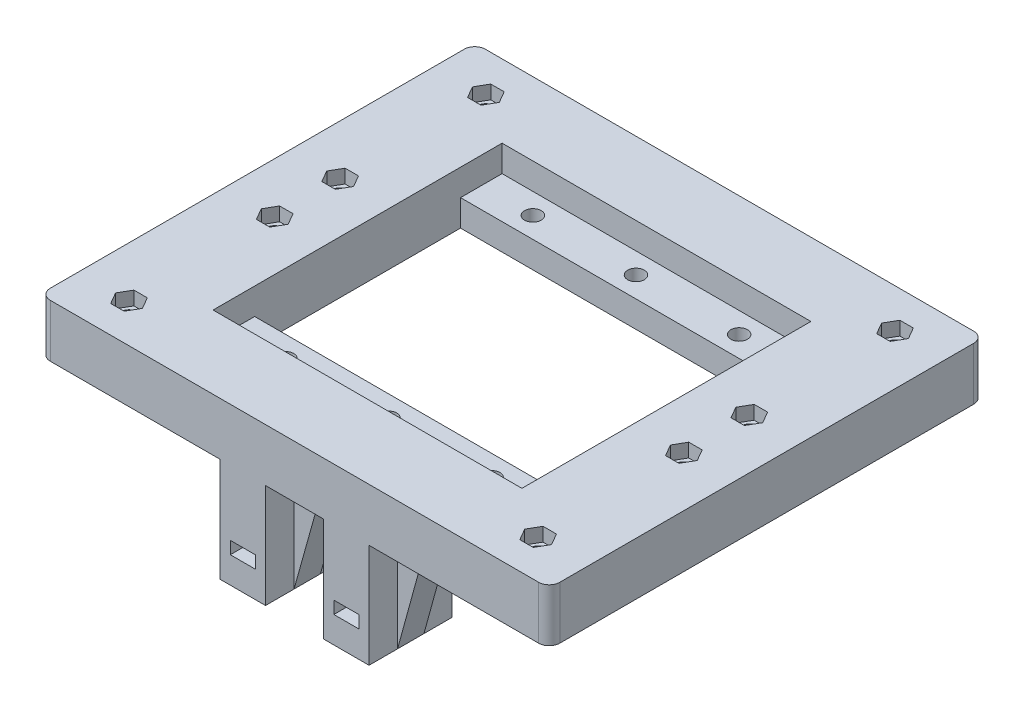
from build123d import *

# Parameters (mm, degrees)
SKETCH2_W            = 122.555
SKETCH2_H            = 104.648
SKETCH2_R            = 2
SKETCH2_W_2          = 74.295
SKETCH2_H_2          = 69.53
BOSS_EXTRUDE5_DEPTH  = 12.7
SKETCH2_4_W          = 74.295
SKETCH2_4_H          = 10
SKETCH2_4_R          = 2
BOSS_EXTRUDE7_DEPTH  = 6.35
CUT_EXTRUDE1_START   = -12.7
SKETCH3_R            = 2
CUT_EXTRUDE1_DEPTH   = 3.302
FILLET1_R            = 2.54
CUT_EXTRUDE2_START   = -6.35
SKETCH4_R            = 2
CUT_EXTRUDE2_DEPTH   = 3.302
SKETCH5_R            = 2
CUT_EXTRUDE3_DEPTH   = 3.302
SKETCH6_R            = 2
CUT_EXTRUDE4_DEPTH   = 3.302
SKETCH7_W            = 10.936
SKETCH7_H            = 20
BOSS_EXTRUDE8_DEPTH  = 25
SKETCH8_R            = 2
CUT_EXTRUDE6_DEPTH   = 19.05
BOSS_EXTRUDE9_START  = -10.033
BOSS_EXTRUDE9_DEPTH  = 3.175
SKETCH10_W           = 6
SKETCH10_H           = 3
CUT_EXTRUDE7_DEPTH   = 8.382
CUT_EXTRUDE15_START  = -20
SKETCH10_3_W         = 6
SKETCH10_3_H         = 3
CUT_EXTRUDE15_DEPTH  = 8.382
SKETCH5_2_R          = 2
BOSS_EXTRUDE10_DEPTH = 6.35
SKETCH6_2_R          = 2
BOSS_EXTRUDE11_DEPTH = 12.7


with BuildPart() as part:
    # Sketch2 → Boss-Extrude5 (new body)
    with BuildSketch(Plane(origin=(0, 0, 0), x_dir=(1, 0, 0), z_dir=(0, 1, 0))):
        with Locations((61.2775, 52.324)):
            Rectangle(SKETCH2_W, SKETCH2_H)
        with Locations(Location((12.065, 95.25, 0), (0, 0, 270))):
            Circle(SKETCH2_R, mode=Mode.SUBTRACT)
        with Locations(Location((12.065, 60.198, 0), (0, 0, 270))):
            Circle(SKETCH2_R, mode=Mode.SUBTRACT)
        with Locations(Location((12.065, 44.45, 0), (0, 0, 270))):
            Circle(SKETCH2_R, mode=Mode.SUBTRACT)
        with Locations(Location((12.065, 9.398, 0), (0, 0, 270))):
            Circle(SKETCH2_R, mode=Mode.SUBTRACT)
        with Locations(Location((110.49, 9.398, 0), (0, 0, 270))):
            Circle(SKETCH2_R, mode=Mode.SUBTRACT)
        with Locations(Location((110.49, 44.45, 0), (0, 0, 270))):
            Circle(SKETCH2_R, mode=Mode.SUBTRACT)
        with Locations(Location((110.49, 60.198, 0), (0, 0, 270))):
            Circle(SKETCH2_R, mode=Mode.SUBTRACT)
        with Locations(Location((110.49, 95.25, 0), (0, 0, 270))):
            Circle(SKETCH2_R, mode=Mode.SUBTRACT)
        with Locations(Location((73.744666667, 5.08, 0), (0, 0, 270))):
            Circle(SKETCH2_R, mode=Mode.SUBTRACT)
        with Locations(Location((48.839129454, 5.150105129, 0), (0, 0, 270))):
            Circle(SKETCH2_R, mode=Mode.SUBTRACT)
        with Locations((61.2775, 52.324)):
            Rectangle(SKETCH2_W_2, SKETCH2_H_2, mode=Mode.SUBTRACT)
    extrude(amount=BOSS_EXTRUDE5_DEPTH)

    # Sketch2_4 → Boss-Extrude7 (add)
    with BuildSketch(Plane(origin=(0, 0, 0), x_dir=(1, 0, 0), z_dir=(0, 1, 0))):
        with Locations((61.2775, 22.559)):
            Rectangle(SKETCH2_4_W, SKETCH2_4_H)
        with Locations(Location((36.533666667, 22.559, 0), (0, 0, 270))):
            Circle(SKETCH2_4_R, mode=Mode.SUBTRACT)
        with Locations(Location((48.939224409, 22.929823378, 0), (0, 0, 270))):
            Circle(SKETCH2_4_R, mode=Mode.SUBTRACT)
        with Locations(Location((61.341, 22.559, 0), (0, 0, 270))):
            Circle(SKETCH2_4_R, mode=Mode.SUBTRACT)
        with Locations(Location((73.744666667, 22.86, 0), (0, 0, 270))):
            Circle(SKETCH2_4_R, mode=Mode.SUBTRACT)
        with Locations(Location((86.148333333, 22.559, 0), (0, 0, 270))):
            Circle(SKETCH2_4_R, mode=Mode.SUBTRACT)
        with Locations((61.2775, 82.089)):
            Rectangle(SKETCH2_4_W, SKETCH2_4_H)
        with Locations(Location((36.533666667, 82.089, 0), (0, 0, 270))):
            Circle(SKETCH2_4_R, mode=Mode.SUBTRACT)
        with Locations(Location((61.341, 82.089, 0), (0, 0, 270))):
            Circle(SKETCH2_4_R, mode=Mode.SUBTRACT)
        with Locations(Location((86.148333333, 82.089, 0), (0, 0, 270))):
            Circle(SKETCH2_4_R, mode=Mode.SUBTRACT)
    extrude(amount=BOSS_EXTRUDE7_DEPTH)

    # Sketch3 → Cut-Extrude1 (cut)
    with BuildSketch(Plane.XZ.offset(CUT_EXTRUDE1_START)):
        Polygon((13.678116652, -6.604), (10.451883348, -6.604), (8.838766696, -9.398), (10.451883348, -12.192), (13.678116652, -12.192), (15.291233304, -9.398), align=None)
        with Locations(Location((12.065, -9.398, 0), (0, 0, 90))):
            Circle(SKETCH3_R, mode=Mode.SUBTRACT)
        Polygon((13.678116652, -92.456), (10.451883348, -92.456), (8.838766696, -95.25), (10.451883348, -98.044), (13.678116652, -98.044), (15.291233304, -95.25), align=None)
        with Locations(Location((12.065, -95.25, 0), (0, 0, 90))):
            Circle(SKETCH3_R, mode=Mode.SUBTRACT)
        Polygon((112.103116652, -92.456), (108.876883348, -92.456), (107.263766696, -95.25), (108.876883348, -98.044), (112.103116652, -98.044), (113.716233304, -95.25), align=None)
        with Locations(Location((110.49, -95.25, 0), (0, 0, 90))):
            Circle(SKETCH3_R, mode=Mode.SUBTRACT)
        Polygon((108.876883348, -12.192), (112.103116652, -12.192), (113.716233304, -9.398), (112.103116652, -6.604), (108.876883348, -6.604), (107.263766696, -9.398), align=None)
        with Locations(Location((110.49, -9.398, 0), (0, 0, 90))):
            Circle(SKETCH3_R, mode=Mode.SUBTRACT)
        Polygon((13.678116652, -62.992), (15.291233304, -60.198), (13.678116652, -57.404), (10.451883348, -57.404), (8.838766696, -60.198), (10.451883348, -62.992), align=None)
        with Locations(Location((12.065, -60.198, 0), (0, 0, 90))):
            Circle(SKETCH3_R, mode=Mode.SUBTRACT)
        Polygon((8.838766696, -44.45), (10.451883348, -47.244), (13.678116652, -47.244), (15.291233304, -44.45), (13.678116652, -41.656), (10.451883348, -41.656), align=None)
        with Locations(Location((12.065, -44.45, 0), (0, 0, 90))):
            Circle(SKETCH3_R, mode=Mode.SUBTRACT)
        Polygon((107.263766696, -44.45), (108.876883348, -47.244), (112.103116652, -47.244), (113.716233304, -44.45), (112.103116652, -41.656), (108.876883348, -41.656), align=None)
        with Locations(Location((110.49, -44.45, 0), (0, 0, 90))):
            Circle(SKETCH3_R, mode=Mode.SUBTRACT)
        Polygon((108.876883348, -57.404), (107.263766696, -60.198), (108.876883348, -62.992), (112.103116652, -62.992), (113.716233304, -60.198), (112.103116652, -57.404), align=None)
        with Locations(Location((110.49, -60.198, 0), (0, 0, 90))):
            Circle(SKETCH3_R, mode=Mode.SUBTRACT)
    extrude(amount=CUT_EXTRUDE1_DEPTH, mode=Mode.SUBTRACT)

    # Fillet1
    fillet1_edges = [part.edges().sort_by_distance(p)[0] for p in [
        (0, 6.35, 0),
        (0, 6.35, -104.648),
        (122.555, 6.35, -104.648),
        (122.555, 6.35, 0),
    ]]
    fillet(fillet1_edges, radius=FILLET1_R)

    # Sketch4 → Cut-Extrude2 (cut)
    with BuildSketch(Plane(origin=(0, 6.35, 0), x_dir=(1, 0, 0), z_dir=(0, 1, 0)).offset(CUT_EXTRUDE2_START)):
        Polygon((39.759899971, 22.559), (38.146783319, 25.353), (34.920550015, 25.353), (33.307433362, 22.559), (34.920550015, 19.765), (38.146783319, 19.765), align=None)
        with Locations(Location((36.533666667, 22.559, 0), (0, 0, 270))):
            Circle(SKETCH4_R, mode=Mode.SUBTRACT)
        Polygon((58.114766696, 22.559), (59.727883348, 19.765), (62.954116652, 19.765), (64.567233304, 22.559), (62.954116652, 25.353), (59.727883348, 25.353), align=None)
        with Locations(Location((61.341, 22.559, 0), (0, 0, 270))):
            Circle(SKETCH4_R, mode=Mode.SUBTRACT)
        Polygon((82.922100029, 22.559), (84.535216681, 19.765), (87.761449985, 19.765), (89.374566638, 22.559), (87.761449985, 25.353), (84.535216681, 25.353), align=None)
        with Locations(Location((86.148333333, 22.559, 0), (0, 0, 270))):
            Circle(SKETCH4_R, mode=Mode.SUBTRACT)
        Polygon((82.922100029, 82.089), (84.535216681, 79.295), (87.761449985, 79.295), (89.374566638, 82.089), (87.761449985, 84.883), (84.535216681, 84.883), align=None)
        with Locations(Location((86.148333333, 82.089, 0), (0, 0, 270))):
            Circle(SKETCH4_R, mode=Mode.SUBTRACT)
        Polygon((64.567233304, 82.089), (62.954116652, 84.883), (59.727883348, 84.883), (58.114766696, 82.089), (59.727883348, 79.295), (62.954116652, 79.295), align=None)
        with Locations(Location((61.341, 82.089, 0), (0, 0, 270))):
            Circle(SKETCH4_R, mode=Mode.SUBTRACT)
        Polygon((39.759899971, 82.089), (38.146783319, 84.883), (34.920550015, 84.883), (33.307433362, 82.089), (34.920550015, 79.295), (38.146783319, 79.295), align=None)
        with Locations(Location((36.533666667, 82.089, 0), (0, 0, 270))):
            Circle(SKETCH4_R, mode=Mode.SUBTRACT)
    extrude(amount=CUT_EXTRUDE2_DEPTH, mode=Mode.SUBTRACT)

    # Sketch5 → Cut-Extrude3 (cut)
    with BuildSketch(Plane(origin=(0, 6.35, 0), x_dir=(1, 0, 0), z_dir=(0, 1, 0))):
        with Locations(Location((48.839129454, 5.150105129, 0), (0, 0, 270))):
            Circle(SKETCH5_R)
        with Locations(Location((73.744666667, 5.08, 0), (0, 0, 270))):
            Circle(SKETCH5_R)
        Polygon((76.970899971, 22.86), (75.357783319, 25.654), (72.131550015, 25.654), (70.518433362, 22.86), (72.131550015, 20.066), (75.357783319, 20.066), align=None)
        with Locations(Location((73.744666667, 22.86, 0), (0, 0, 270))):
            Circle(SKETCH5_R, mode=Mode.SUBTRACT)
        Polygon((52.165457714, 22.929823378), (50.552341061, 25.723823378), (47.326107757, 25.723823378), (45.712991105, 22.929823378), (47.326107757, 20.135823378), (50.552341061, 20.135823378), align=None)
        with Locations(Location((48.939224409, 22.929823378, 0), (0, 0, 270))):
            Circle(SKETCH5_R, mode=Mode.SUBTRACT)
    extrude(amount=-CUT_EXTRUDE3_DEPTH, mode=Mode.SUBTRACT)

    # Sketch6 → Cut-Extrude4 (cut)
    with BuildSketch(Plane(origin=(0, 12.7, 0), x_dir=(1, 0, 0), z_dir=(0, 1, 0))):
        Polygon((70.518433362, 5.08), (72.131550015, 2.286), (75.357783319, 2.286), (76.970899971, 5.08), (75.357783319, 7.874), (72.131550015, 7.874), align=None)
        with Locations(Location((73.744666667, 5.08, 0), (0, 0, 270))):
            Circle(SKETCH6_R, mode=Mode.SUBTRACT)
        Polygon((45.612896149, 5.150105129), (47.226012801, 2.356105129), (50.452246106, 2.356105129), (52.065362758, 5.150105129), (50.452246106, 7.944105129), (47.226012801, 7.944105129), align=None)
        with Locations(Location((48.839129454, 5.150105129, 0), (0, 0, 270))):
            Circle(SKETCH6_R, mode=Mode.SUBTRACT)
    extrude(amount=-CUT_EXTRUDE4_DEPTH, mode=Mode.SUBTRACT)

    # Sketch7 → Boss-Extrude8 (add)
    with BuildSketch(Plane.XZ):
        with Locations((48.839129454, -10)):
            Rectangle(SKETCH7_W, SKETCH7_H)
        with Locations((73.744666667, -10)):
            Rectangle(SKETCH7_W, SKETCH7_H)
    extrude(amount=BOSS_EXTRUDE8_DEPTH)

    # Sketch8 → Cut-Extrude6 (cut)
    with BuildSketch(Plane.XZ.offset(25)):
        with Locations(Location((48.839129454, -15.310105129, 0), (0, 0, 270))):
            Circle(SKETCH8_R)
        with Locations(Location((48.839129454, -5.150105129, 0), (0, 0, 270))):
            Circle(SKETCH8_R)
        with Locations(Location((73.744666667, -5.08, 0), (0, 0, 90))):
            Circle(SKETCH8_R)
        with Locations(Location((73.744666667, -15.310105129, 0), (0, 0, 270))):
            Circle(SKETCH8_R)
    extrude(amount=-CUT_EXTRUDE6_DEPTH, mode=Mode.SUBTRACT)

    # Sketch9 → Boss-Extrude9 (add, symmetric)
    with BuildSketch(Plane.XY.offset(BOSS_EXTRUDE9_START)):
        Polygon((68.276666667, 0), (61.29189806, 0), (68.276666667, -25), align=None)
        Polygon((79.212666667, 0), (79.212666667, -25), (86.070666667, 0), align=None)
        Polygon((54.307129454, 0), (54.307129454, -25), (61.29189806, 0), align=None)
        Polygon((43.371129454, 0), (36.513129454, 0), (43.371129454, -25), align=None)
    extrude(amount=BOSS_EXTRUDE9_DEPTH, both=True)

    # Sketch10 → Cut-Extrude7 (cut)
    with BuildSketch(Plane.XY):
        with Locations((48.839129454, -17.15)):
            Rectangle(SKETCH10_W, SKETCH10_H)
        with Locations((73.744666667, -17.15)):
            Rectangle(SKETCH10_W, SKETCH10_H)
    extrude(amount=-CUT_EXTRUDE7_DEPTH, mode=Mode.SUBTRACT)

    # Sketch10_3 → Cut-Extrude15 (cut)
    with BuildSketch(Plane.XY.offset(CUT_EXTRUDE15_START)):
        with Locations((48.839129454, -17.15)):
            Rectangle(SKETCH10_3_W, SKETCH10_3_H)
        with Locations((73.744666667, -17.15)):
            Rectangle(SKETCH10_3_W, SKETCH10_3_H)
    extrude(amount=CUT_EXTRUDE15_DEPTH, mode=Mode.SUBTRACT)

    # Sketch5_2 → Boss-Extrude10 (add)
    with BuildSketch(Plane(origin=(0, 6.35, 0), x_dir=(1, 0, 0), z_dir=(0, 1, 0))):
        Polygon((47.326107757, 20.135823378), (50.552341061, 20.135823378), (52.165457714, 22.929823378), (50.552341061, 25.723823378), (47.326107757, 25.723823378), (45.712991105, 22.929823378), align=None)
        with Locations((48.939224409, 22.929823378)):
            Circle(SKETCH5_2_R, mode=Mode.SUBTRACT)
        with Locations((48.939224409, 22.929823378)):
            Circle(SKETCH5_2_R)
        Polygon((72.131550015, 20.066), (75.357783319, 20.066), (76.970899971, 22.86), (75.357783319, 25.654), (72.131550015, 25.654), (70.518433362, 22.86), align=None)
        with Locations((73.744666667, 22.86)):
            Circle(SKETCH5_2_R, mode=Mode.SUBTRACT)
        with Locations((73.744666667, 22.86)):
            Circle(SKETCH5_2_R)
    extrude(amount=-BOSS_EXTRUDE10_DEPTH)

    # Sketch6_2 → Boss-Extrude11 (add)
    with BuildSketch(Plane(origin=(0, 12.7, 0), x_dir=(1, 0, 0), z_dir=(0, 1, 0))):
        Polygon((50.452246106, 7.944105129), (47.226012801, 7.944105129), (45.612896149, 5.150105129), (47.226012801, 2.356105129), (50.452246106, 2.356105129), (52.065362758, 5.150105129), align=None)
        with Locations(Location((48.839129454, 5.150105129, 0), (0, 0, 90))):
            Circle(SKETCH6_2_R, mode=Mode.SUBTRACT)
        with Locations(Location((48.839129454, 5.150105129, 0), (0, 0, 90))):
            Circle(SKETCH6_2_R)
        Polygon((75.357783319, 7.874), (72.131550015, 7.874), (70.518433362, 5.08), (72.131550015, 2.286), (75.357783319, 2.286), (76.970899971, 5.08), align=None)
        with Locations(Location((73.744666667, 5.08, 0), (0, 0, 90))):
            Circle(SKETCH6_2_R, mode=Mode.SUBTRACT)
        with Locations(Location((73.744666667, 5.08, 0), (0, 0, 90))):
            Circle(SKETCH6_2_R)
    extrude(amount=-BOSS_EXTRUDE11_DEPTH)


solid = part.part
